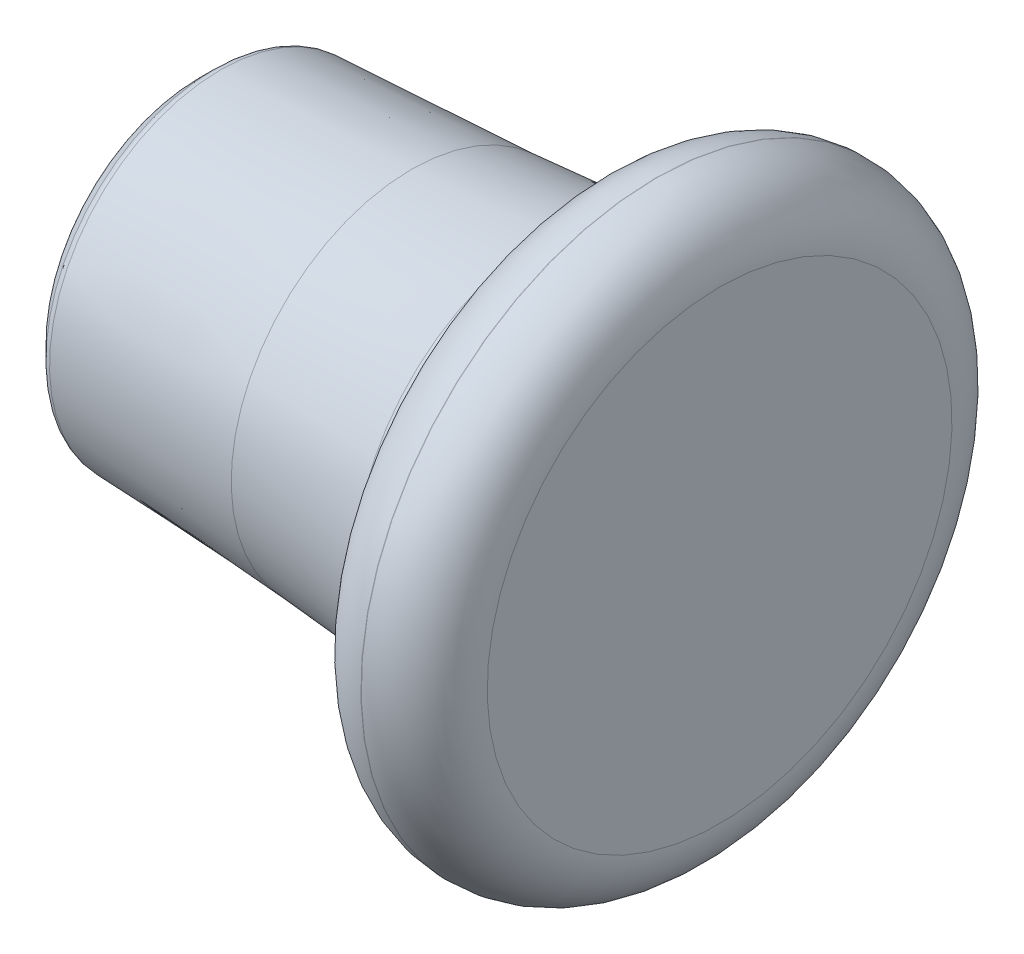
from build123d import *


with BuildPart() as part:
    # Sketch2 → Revolve1 (revolve)
    with BuildSketch(Plane.XY):
        with BuildLine():
            Line((-126.767029403, 81.676904789), (-78.228933631, 79.25))
            ThreePointArc((-78.228933631, 79.25), (-60.619483805, 77.84878425), (-43.123035518, 75.413537626))
            ThreePointArc((-43.123035518, 75.413537626), (-41.060447751, 74.831340884), (-39.169286378, 73.823010577))
            ThreePointArc((-39.169286378, 73.823010577), (-35.312933401, 70.206346657), (-32.754159078, 65.579858771))
            Line((-32.754159078, 65.579858771), (-32.056761325, 63.663774193))
            ThreePointArc((-32.056761325, 63.663774193), (-31.860334358, 63.066262055), (-31.701859109, 62.457583237))
            ThreePointArc((-31.701859109, 62.457583237), (-26.081952508, 53.496427146), (-16.098933631, 50))
            Line((-16.098933631, 50), (-16, 50))
            ThreePointArc((-16, 50), (-4.686291501, 54.686291501), (0, 66))
            Line((0, 66), (0, 78.5))
            Line((0, 78.5), (0, 125))
            Line((0, 125), (-132.728933631, 125))
            Line((-132.728933631, 125), (-132.728933631, 97.760533906))
            Line((-132.728933631, 97.760533906), (-132.728933631, 87.760533906))
            ThreePointArc((-132.728933631, 87.760533906), (-132.538632462, 86.803825325), (-131.996700584, 85.992766953))
            Line((-131.996700584, 85.992766953), (-128.409952314, 82.406018683))
            ThreePointArc((-128.409952314, 82.406018683), (-127.656283908, 81.888702675), (-126.767029403, 81.676904789))
        make_face()
    revolve(axis=Axis((0, 125, 0), (-1, 0, 0)))


solid = part.part
